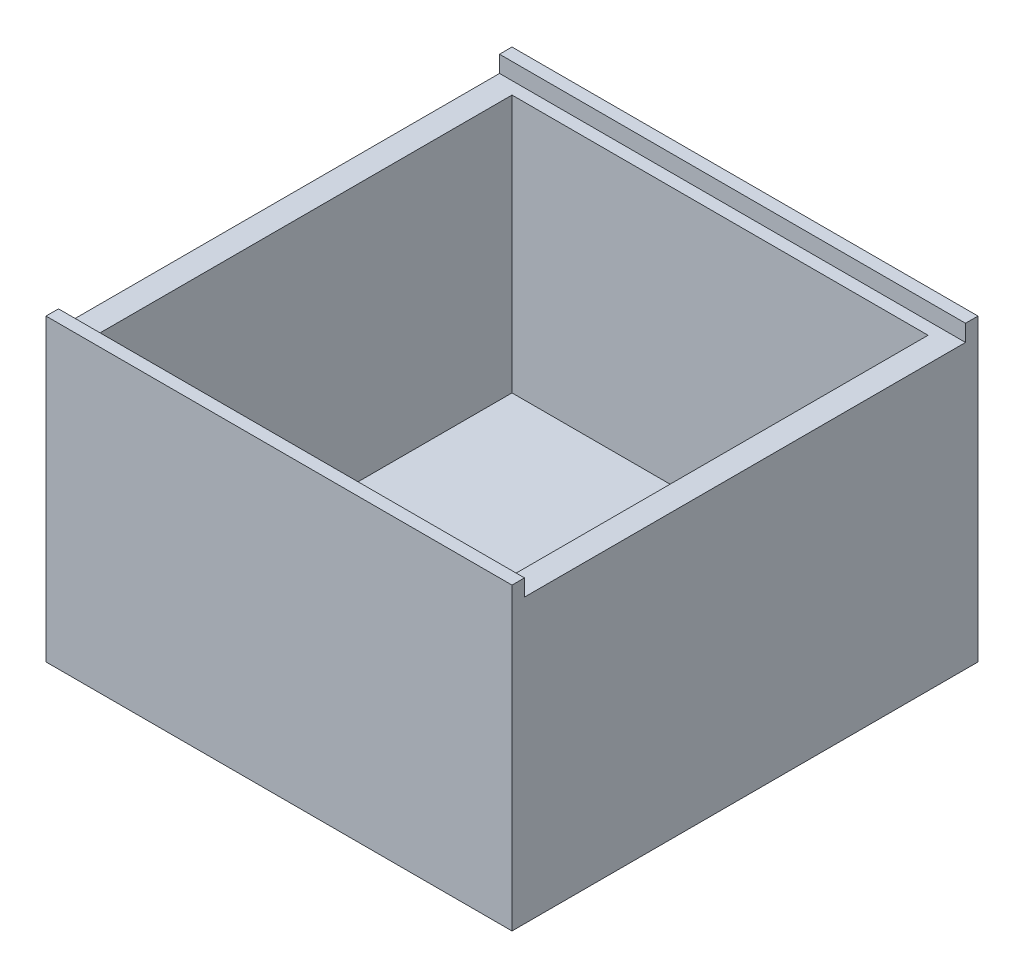
from build123d import *

# Parameters (mm, degrees)
SKETCH1_W           = 28
SKETCH1_H           = 28
BOSS_EXTRUDE1_DEPTH = 18
SHELL2_T            = -1.5
SKETCH2_W           = 26.5
SKETCH2_H           = 1
CUT_EXTRUDE1_DEPTH  = 29


with BuildPart() as part:
    # Sketch1 → Boss-Extrude1 (new body)
    with BuildSketch(Plane(origin=(0, 0, 0), x_dir=(1, 0, 0), z_dir=(0, 1, 0))):
        Rectangle(SKETCH1_W, SKETCH1_H)
    extrude(amount=BOSS_EXTRUDE1_DEPTH)

    # Shell2
    shell2_openings = [part.faces().sort_by_distance(p)[0] for p in [
        (0, 18, 0),
    ]]
    offset(amount=SHELL2_T, openings=shell2_openings, kind=Kind.INTERSECTION)

    # Sketch2 → Cut-Extrude1 (cut, through all)
    with BuildSketch(Plane.ZY.offset(14)):
        with Locations((0, 17.5)):
            Rectangle(SKETCH2_W, SKETCH2_H)
    extrude(amount=-CUT_EXTRUDE1_DEPTH, mode=Mode.SUBTRACT)


solid = part.part
